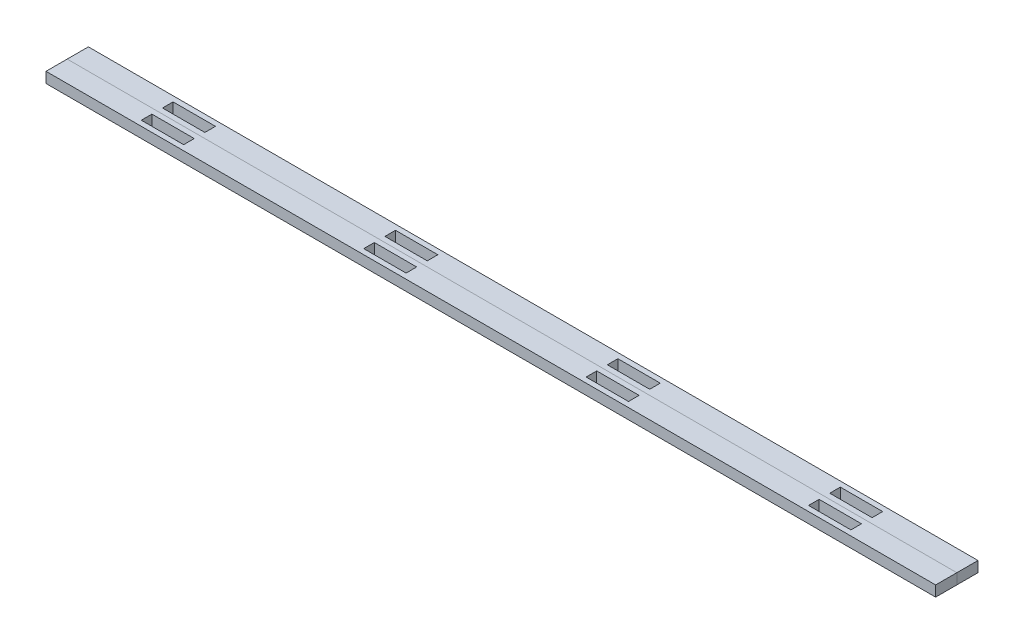
from build123d import *

# Parameters (mm, degrees)
SKETCH1_W           = 533.4
SKETCH1_H           = 12.7
BOSS_EXTRUDE1_DEPTH = 6.35
SKETCH2_W           = 25.4
SKETCH2_H           = 6.35
CUT_EXTRUDE1_DEPTH  = 7.35
LPATTERN1_COUNT     = 4
LPATTERN1_PITCH     = 133.35
LPATTERN2_COUNT     = 2
LPATTERN2_PITCH     = 12.7


with BuildPart() as part:
    # Sketch1 → Boss-Extrude1 (new body)
    with BuildSketch(Plane(origin=(0, 0, 0), x_dir=(1, 0, 0), z_dir=(0, 1, 0))):
        Rectangle(SKETCH1_W, SKETCH1_H)
    extrude(amount=BOSS_EXTRUDE1_DEPTH)

    # Sketch2 → Cut-Extrude1 (cut, through all)
    with BuildSketch(Plane(origin=(0, 6.35, 0), x_dir=(1, 0, 0), z_dir=(0, 1, 0))):
        with Locations((-200.025, 0)):
            Rectangle(SKETCH2_W, SKETCH2_H)
    cut_extrude1 = extrude(amount=-CUT_EXTRUDE1_DEPTH, mode=Mode.SUBTRACT)

    # LPattern1: Cut-Extrude1 ×4
    with Locations(*[(i * LPATTERN1_PITCH, 0, 0) for i in range(1, LPATTERN1_COUNT)]):
        add(cut_extrude1, mode=Mode.SUBTRACT)


with BuildPart() as lpattern2_1:
    # LPattern2: pattern copy
    add(part.part.moved(Location(Vector(0, 0, 1) * (1 * LPATTERN2_PITCH))))


solid = Compound([part.part, lpattern2_1.part])
